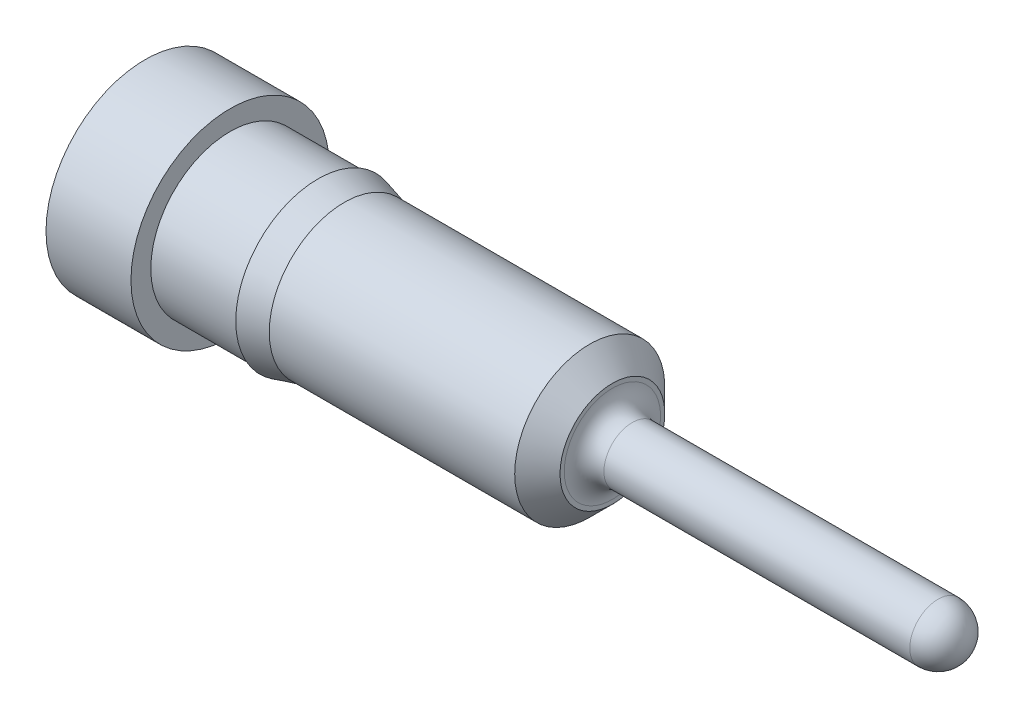
from build123d import *


with BuildPart() as part:
    # Sketch1 → RevolutionAngle1 (revolve)
    with BuildSketch(Plane.XY):
        with BuildLine():
            Line((4.191, 0.4699), (4.191, 0.4318))
            ThreePointArc((4.191, 0.4318), (4.243076414, 0.306076414), (4.3688, 0.254))
            Line((4.3688, 0.254), (7.112, 0.254))
            ThreePointArc((7.112, 0.254), (7.291605122, 0.179605122), (7.366, 0))
            Line((7.366, 0), (0, 0))
            Line((0, 0), (0, 0.889))
            Line((0, 0.889), (0.762, 0.889))
            Line((0.762, 0.889), (0.762, 0.7112))
            Line((0.762, 0.7112), (1.5494, 0.7112))
            Line((1.5494, 0.7112), (1.5494, 0.7366))
            Line((1.5494, 0.7366), (1.786385226, 0.6731))
            Line((1.786385226, 0.6731), (3.9878, 0.6731))
            Line((3.9878, 0.6731), (4.191, 0.4699))
        make_face()
    revolve(axis=Axis((0, 0, 0), (1, 0, 0)))


solid = part.part
